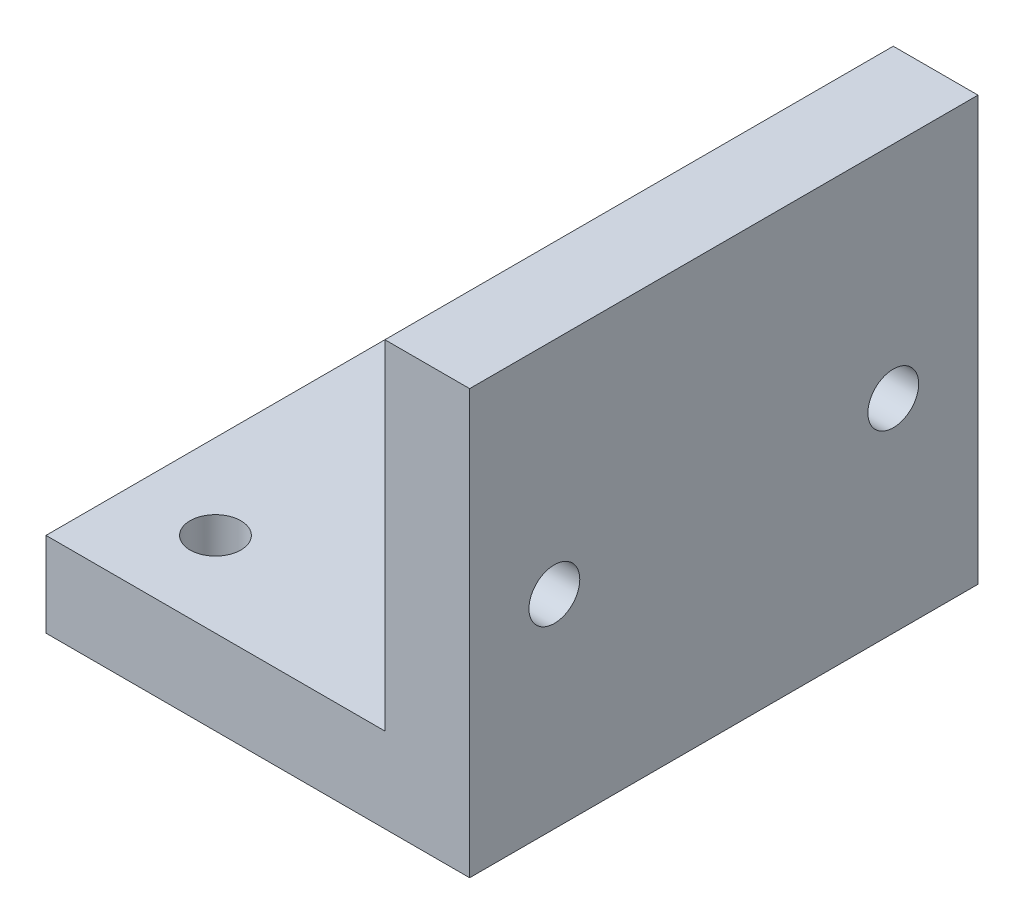
from build123d import *

# Parameters (mm, degrees)
SALIENTE_EXTRUIR1_DEPTH = 30
CROQUIS2_R              = 1.5
CORTAR_EXTRUIR1_DEPTH   = 30
CROQUIS3_R              = 1.5
CORTAR_EXTRUIR2_DEPTH   = 30


with BuildPart() as part:
    # Croquis1 → Saliente-Extruir1 (new body)
    with BuildSketch(Plane.XY):
        Polygon((0, 0), (20, 0), (20, 20), (25, 20), (25, -5), (0, -5), align=None)
    extrude(amount=SALIENTE_EXTRUIR1_DEPTH)

    # Croquis2 → Cortar-Extruir1 (cut)
    with BuildSketch(Plane(origin=(25, 0, 0), x_dir=(0, 0, -1), z_dir=(1, 0, 0))):
        with Locations((-25, 7)):
            Circle(CROQUIS2_R)
        with Locations((-5, 7)):
            Circle(CROQUIS2_R)
    extrude(amount=-CORTAR_EXTRUIR1_DEPTH, mode=Mode.SUBTRACT)

    # Croquis3 → Cortar-Extruir2 (cut)
    with BuildSketch(Plane.XZ.offset(5)):
        with Locations((5, 5)):
            Circle(CROQUIS3_R)
        with Locations((5, 25)):
            Circle(CROQUIS3_R)
    extrude(amount=-CORTAR_EXTRUIR2_DEPTH, mode=Mode.SUBTRACT)


solid = part.part
